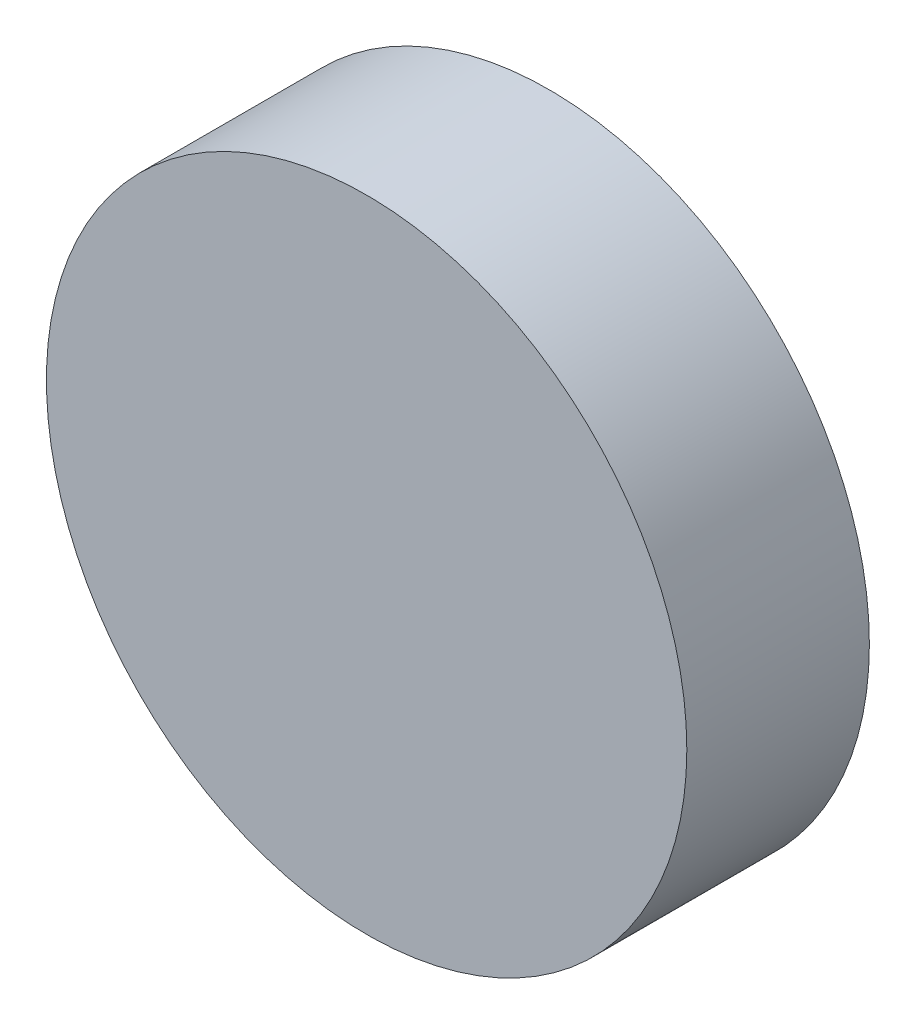
from build123d import *

# Parameters (mm, degrees)
SKIZZE1_R                       = 87.697711293
AUFSATZ_LINEAR_AUSTRAGEN1_DEPTH = 50


with BuildPart() as part:
    # Skizze1 → Aufsatz-Linear austragen1 (new body)
    with BuildSketch(Plane.XY):
        Circle(SKIZZE1_R)
    extrude(amount=AUFSATZ_LINEAR_AUSTRAGEN1_DEPTH)


solid = part.part
